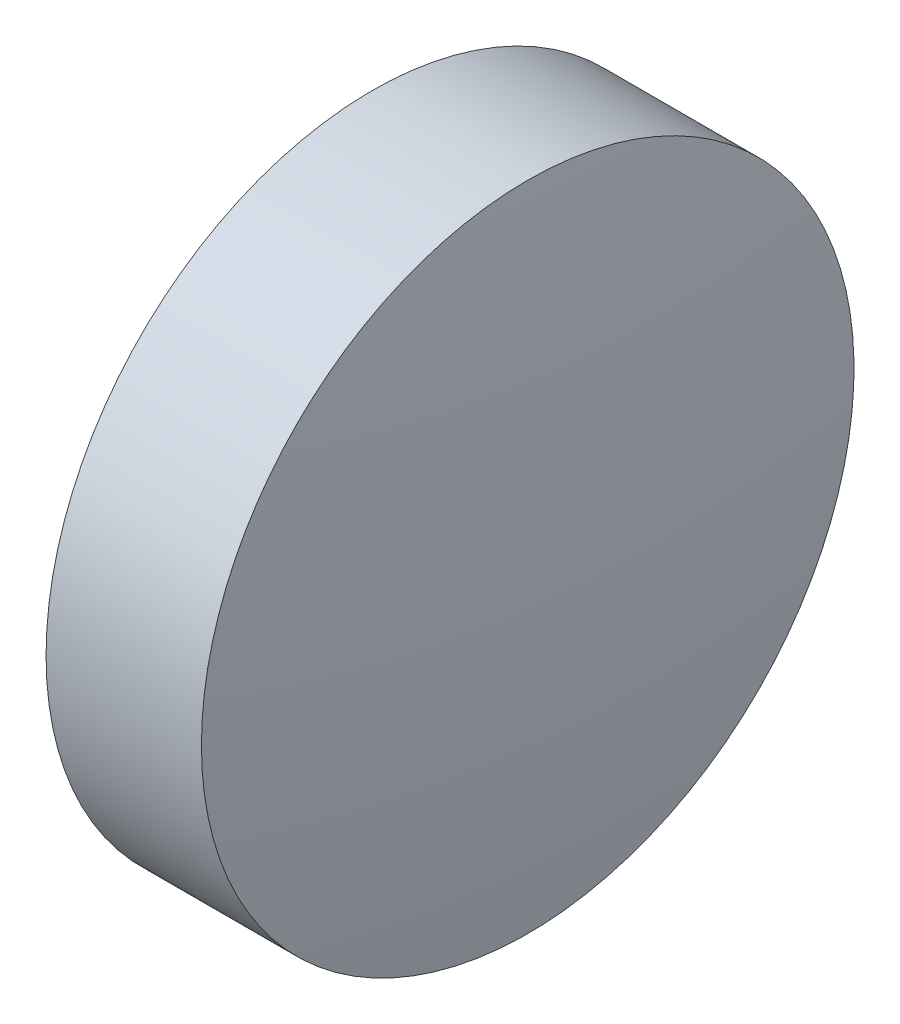
from build123d import *


with BuildPart() as part:
    # 草图1 → 旋转1 (revolve)
    with BuildSketch(Plane.XY):
        with BuildLine():
            Line((401.325327277, 121.052591536), (401.325327277, 124.202591536))
            Line((401.325327277, 124.202591536), (402.825327277, 124.202591536))
            ThreePointArc((402.825327277, 124.202591536), (402.990260371, 122.631428133), (403.045327277, 121.052591536))
            Line((403.045327277, 121.052591536), (401.325327277, 121.052591536))
        make_face()
    revolve(axis=Axis((400.464689189, 121.052591536, 0), (1, 0, 0)))


solid = part.part
